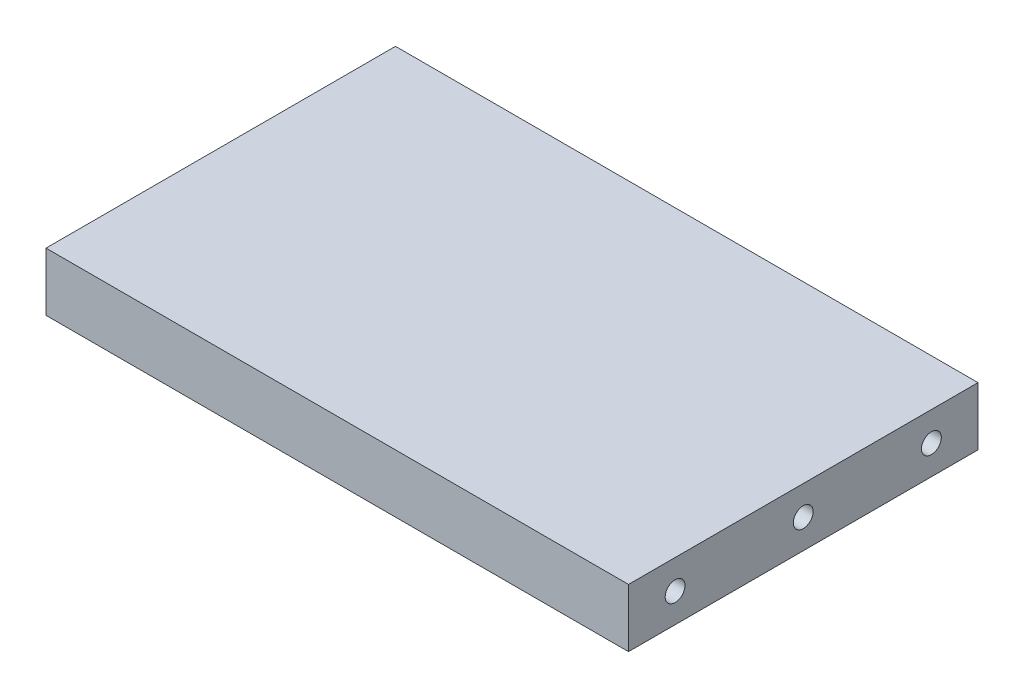
from build123d import *

# Parameters (mm, degrees)
SKETCH1_W                      = 100
SKETCH1_H                      = 60
BOSS_EXTRUDE1_DEPTH            = 10
CBORE_FOR_M3_SHCS1_D           = 3.4
CBORE_FOR_M3_SHCS1_DEPTH       = 23
CBORE_FOR_M3_SHCS1_CBORE_D     = 6.5
CBORE_FOR_M3_SHCS1_CBORE_DEPTH = 3
CBORE_FOR_M3_SHCS1_TIP         = 1.021463052
CBORE_FOR_M3_SHCS2_D           = 3.4
CBORE_FOR_M3_SHCS2_DEPTH       = 23
CBORE_FOR_M3_SHCS2_CBORE_D     = 6.5
CBORE_FOR_M3_SHCS2_CBORE_DEPTH = 3
CBORE_FOR_M3_SHCS2_TIP         = 1.021463052


with BuildPart() as part:
    # Sketch1 → Boss-Extrude1 (new body)
    with BuildSketch(Plane(origin=(0, 0, 0), x_dir=(1, 0, 0), z_dir=(0, 1, 0))):
        Rectangle(SKETCH1_W, SKETCH1_H)
    extrude(amount=BOSS_EXTRUDE1_DEPTH)

    # CBORE for M3 SHCS1
    with Locations(Plane(origin=(60, -888.012147263, -1303.282701689), x_dir=(0, 0, -1), z_dir=(1, 0, 0))):
        with Locations((-1281.282701689, 893.012147263), (-1325.282701689, 893.012147263), (-1303.282701689, 893.012147263)):
            CounterBoreHole(CBORE_FOR_M3_SHCS1_D / 2, CBORE_FOR_M3_SHCS1_CBORE_D / 2, CBORE_FOR_M3_SHCS1_CBORE_DEPTH, depth=CBORE_FOR_M3_SHCS1_DEPTH)
            with Locations((0, 0, -(CBORE_FOR_M3_SHCS1_DEPTH + CBORE_FOR_M3_SHCS1_TIP / 2))):  # 118° drill point
                Cone(0, CBORE_FOR_M3_SHCS1_D / 2, CBORE_FOR_M3_SHCS1_TIP, mode=Mode.SUBTRACT)

    # CBORE for M3 SHCS2
    with Locations(Plane(origin=(-60, -888.012147263, -1303.282701689), x_dir=(0, 0, 1), z_dir=(-1, 0, 0))):
        with Locations((1281.282701689, 893.012147263), (1325.282701689, 893.012147263), (1303.282701689, 893.012147263)):
            CounterBoreHole(CBORE_FOR_M3_SHCS2_D / 2, CBORE_FOR_M3_SHCS2_CBORE_D / 2, CBORE_FOR_M3_SHCS2_CBORE_DEPTH, depth=CBORE_FOR_M3_SHCS2_DEPTH)
            with Locations((0, 0, -(CBORE_FOR_M3_SHCS2_DEPTH + CBORE_FOR_M3_SHCS2_TIP / 2))):  # 118° drill point
                Cone(0, CBORE_FOR_M3_SHCS2_D / 2, CBORE_FOR_M3_SHCS2_TIP, mode=Mode.SUBTRACT)


solid = part.part
